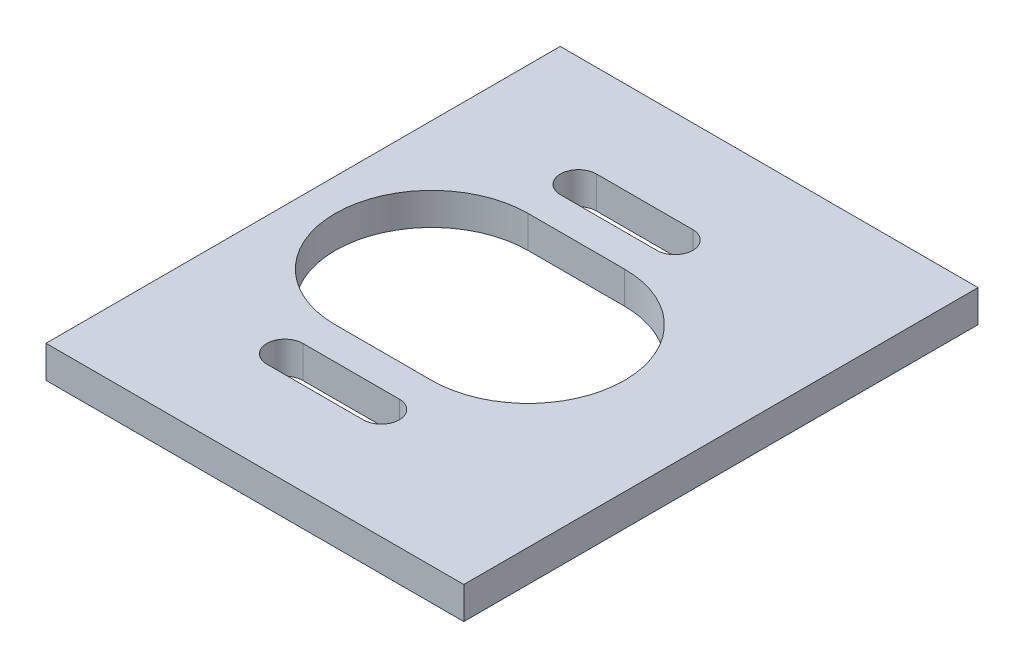
from build123d import *

# Parameters (mm, degrees)
SKETCH1_W           = 177.8
SKETCH1_H           = 50.8
BOSS_EXTRUDE1_DEPTH = 3.175
CUT_EXTRUDE1_DEPTH  = 3.175
SKETCH6_W           = 142.875
SKETCH6_H           = 50.8
CUT_EXTRUDE3_DEPTH  = 3.175
SKETCH8_W           = 50.8
SKETCH8_H           = 3.175
BOSS_EXTRUDE2_DEPTH = 6.35


with BuildPart() as part:
    # Sketch1 → Boss-Extrude1 (new body)
    with BuildSketch(Plane(origin=(0, 0, 0), x_dir=(1, 0, 0), z_dir=(0, 1, 0))):
        Rectangle(SKETCH1_W, SKETCH1_H)
    extrude(amount=BOSS_EXTRUDE1_DEPTH)

    # Sketch2 → Cut-Extrude1 (cut)
    with BuildSketch(Plane(origin=(0, 3.175, 0), x_dir=(1, 0, 0), z_dir=(0, 1, 0))):
        with BuildLine():
            Line((-76.2, -12.722), (-66.675, -12.722))
            ThreePointArc((-66.675, -12.722), (-64.897, -14.5), (-66.675, -16.278))
            Line((-66.675, -16.278), (-76.2, -16.278))
            ThreePointArc((-76.2, -16.278), (-77.978, -14.5), (-76.2, -12.722))
        make_face()
        with BuildLine():
            Line((-66.675, 12.722), (-76.2, 12.722))
            ThreePointArc((-76.2, 12.722), (-77.978, 14.5), (-76.2, 16.278))
            Line((-76.2, 16.278), (-66.675, 16.278))
            ThreePointArc((-66.675, 16.278), (-64.897, 14.5), (-66.675, 12.722))
        make_face()
        with BuildLine():
            Line((-66.675, -9.525), (-76.2, -9.525))
            ThreePointArc((-76.2, -9.525), (-85.725, 0), (-76.2, 9.525))
            Line((-76.2, 9.525), (-66.675, 9.525))
            ThreePointArc((-66.675, 9.525), (-57.15, 0), (-66.675, -9.525))
        make_face()
    cut_extrude1 = extrude(amount=-CUT_EXTRUDE1_DEPTH, mode=Mode.SUBTRACT)

    # Mirror1: Cut-Extrude1 across plane
    add(cut_extrude1.mirror(Plane(origin=(0, 0, 0), x_dir=(0, 0, 1), z_dir=(1, 0, 0))), mode=Mode.SUBTRACT)

    # Sketch6 → Cut-Extrude3 (cut)
    with BuildSketch(Plane(origin=(0, 3.175, 0), x_dir=(1, 0, 0), z_dir=(0, 1, 0))):
        with Locations((-17.4625, 0)):
            Rectangle(SKETCH6_W, SKETCH6_H)
    extrude(amount=-CUT_EXTRUDE3_DEPTH, mode=Mode.SUBTRACT)

    # Sketch8 → Boss-Extrude2 (add)
    with BuildSketch(Plane(origin=(88.9, 0, 0), x_dir=(0, 0, -1), z_dir=(1, 0, 0))):
        with Locations((0, 1.5875)):
            Rectangle(SKETCH8_W, SKETCH8_H)
    extrude(amount=BOSS_EXTRUDE2_DEPTH)


solid = part.part
